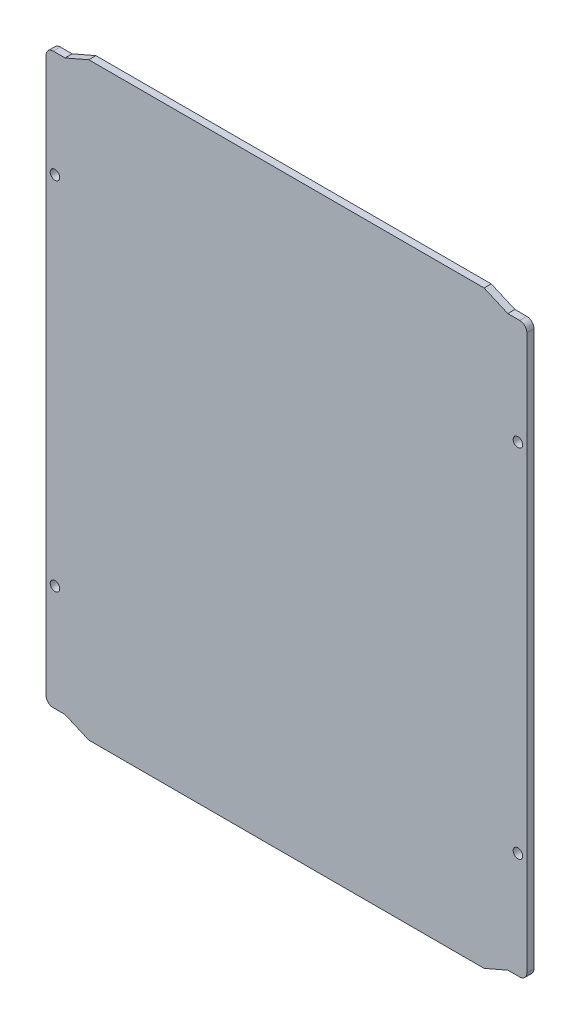
from build123d import *

# Parameters (mm, degrees)
BOSS_EXTRUDE1_DEPTH   = 3
F_4_0MM_DOWEL_HOLE1_D = 4


with BuildPart() as part:
    # Sketch1 → Boss-Extrude1 (new body)
    with BuildSketch(Plane.XY):
        with BuildLine():
            Line((0, 7.34), (0, 240.84))
            ThreePointArc((0, 240.84), (0.878679656, 242.961320344), (3, 243.84))
            Line((3, 243.84), (8, 243.84))
            Line((8, 243.84), (18, 248.18))
            Line((18, 248.18), (184.5, 248.18))
            Line((184.5, 248.18), (194.5, 243.84))
            Line((194.5, 243.84), (199.5, 243.84))
            ThreePointArc((199.5, 243.84), (201.621320344, 242.961320344), (202.5, 240.84))
            Line((202.5, 240.84), (202.5, 7.34))
            ThreePointArc((202.5, 7.34), (201.621320344, 5.218679656), (199.5, 4.34))
            Line((199.5, 4.34), (194.5, 4.34))
            Line((194.5, 4.34), (184.5, 0))
            Line((184.5, 0), (18, 0))
            Line((18, 0), (8, 4.34))
            Line((8, 4.34), (3, 4.34))
            ThreePointArc((3, 4.34), (0.878679656, 5.218679656), (0, 7.34))
        make_face()
    extrude(amount=BOSS_EXTRUDE1_DEPTH)

    # Ø4.0mm Dowel Hole1 (through all)
    with Locations(Plane.XY.offset(3)):
        with Locations((3.75, 199.09), (3.75, 49.09), (198.75, 49.09), (198.75, 199.09)):
            Hole(F_4_0MM_DOWEL_HOLE1_D / 2)


solid = part.part
